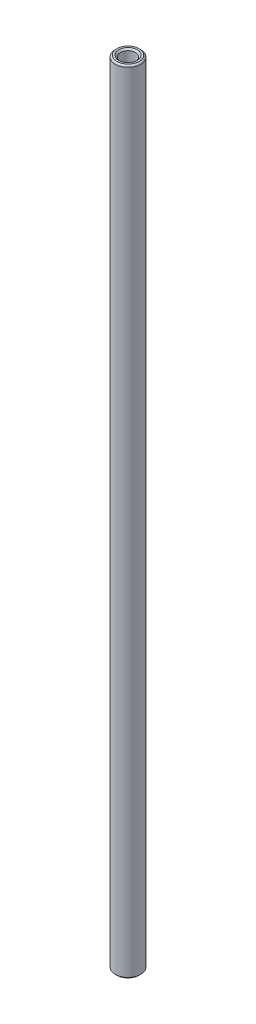
from build123d import *

# Parameters (mm, degrees)
SKETCH1_R           = 1.984375
SKETCH1_R_2         = 1.190625
BOSS_EXTRUDE1_DEPTH = 61.9125
CHAMFER1_SIZE       = 0.254


with BuildPart() as part:
    # Sketch1 → Boss-Extrude1 (new body, symmetric)
    with BuildSketch(Plane(origin=(0, 0, 0), x_dir=(1, 0, 0), z_dir=(0, 1, 0))):
        Circle(SKETCH1_R)
        Circle(SKETCH1_R_2, mode=Mode.SUBTRACT)
    extrude(amount=BOSS_EXTRUDE1_DEPTH, both=True)

    # Chamfer1
    chamfer1_edges = [part.edges().sort_by_distance(p)[0] for p in [
        (-1.984375, -61.9125, 0),
        (-1.984375, 61.9125, 0),
        (-1.190625, -61.9125, 0),
        (-1.190625, 61.9125, 0),
    ]]
    chamfer(chamfer1_edges, length=CHAMFER1_SIZE)


solid = part.part
